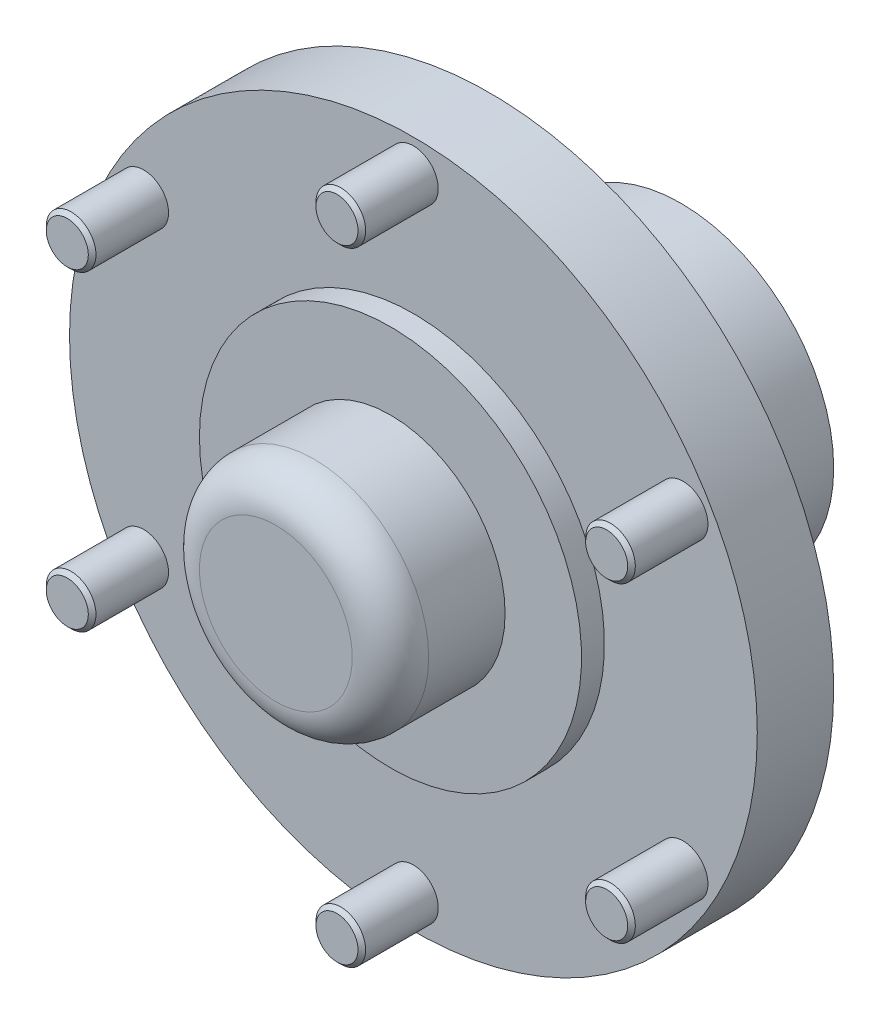
from build123d import *
from OCP.BRepFilletAPI import BRepFilletAPI_MakeFillet

# Parameters (mm, degrees)
SKETCH7_R           = 6.5
BOSS_EXTRUDE2_DEPTH = 20
FILLET2_R1          = 25
FILLET2_R2          = 10
CHAMFER1_SIZE       = 1


with BuildPart() as part:
    # Sketch6 → Revolve2 (revolve)
    with BuildSketch(Plane(origin=(0, 0, -433528.712964682), x_dir=(-1, 0, 0), z_dir=(0, -1, 0))):
        Polygon((-30, -433528.712964682), (0, -433528.712964682), (0, -433452.712964682), (-30, -433452.712964682), (-30, -433422.712964682), (-40, -433422.712964682), (-40, -433472.712964682), (-90, -433472.712964682), (-90, -433492.712964682), (-50, -433492.712964682), (-50, -433498.712964682), (-30, -433498.712964682), align=None)
    revolve(axis=Axis((0, 0, 0), (0, 0, -1)))

    # Sketch7 → Boss-Extrude2 (add)
    with BuildSketch(Plane(origin=(0, 0, -36), x_dir=(-1, 0, 0), z_dir=(0, 0, 1))):
        with Locations((70.581070408, 40.75)):
            Circle(SKETCH7_R)
        with Locations((0, 81.5)):
            Circle(SKETCH7_R)
        with Locations((70.581070408, -40.75)):
            Circle(SKETCH7_R)
        with Locations((0, -81.5)):
            Circle(SKETCH7_R)
        with Locations((-70.581070408, -40.75)):
            Circle(SKETCH7_R)
        with Locations((-70.581070408, 40.75)):
            Circle(SKETCH7_R)
    extrude(amount=BOSS_EXTRUDE2_DEPTH)

    # Fillet2: one fillet with a radius per group of edges: ONE call of the kernel's fillet builder (fillet() takes one radius for all edges)
    fillet2_edges_1 = [part.edges().sort_by_distance(p)[0] for p in [
        (-40, 0, -56),
    ]]
    fillet2_edges_2 = [part.edges().sort_by_distance(p)[0] for p in [
        (-30, 0, 0),
    ]]
    fillet2 = BRepFilletAPI_MakeFillet(part.part.solid().wrapped)
    for e in fillet2_edges_1:
        fillet2.Add(FILLET2_R1, e.wrapped)
    for e in fillet2_edges_2:
        fillet2.Add(FILLET2_R2, e.wrapped)
    add(Compound.cast(fillet2.Shape()), mode=Mode.REPLACE)

    # Chamfer1
    chamfer1_edges = [part.edges().sort_by_distance(p)[0] for p in [
        (-64.081070408, -40.75, -16),
        (77.081070408, 40.75, -16),
        (77.081070408, -40.75, -16),
        (6.5, -81.5, -16),
        (6.5, 81.5, -16),
        (-64.081070408, 40.75, -16),
    ]]
    chamfer(chamfer1_edges, length=CHAMFER1_SIZE)


solid = part.part
